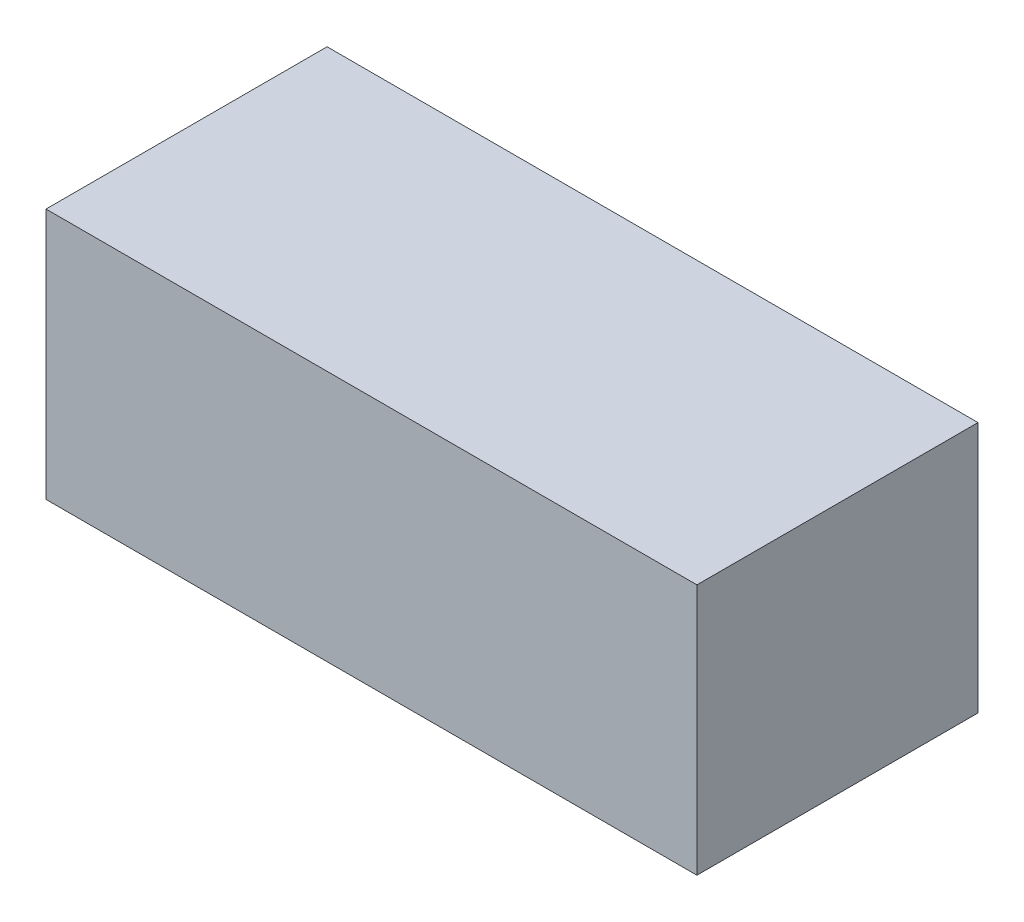
from build123d import *

# Parameters (mm, degrees)
SKETCH1_W           = 4.4
SKETCH1_H           = 1.9
BOSS_EXTRUDE1_DEPTH = 1.7


with BuildPart() as part:
    # Sketch1 → Boss-Extrude1 (new body)
    with BuildSketch(Plane(origin=(0, 0, 0), x_dir=(1, 0, 0), z_dir=(0, 1, 0))):
        with Locations((2.2, 0.95)):
            Rectangle(SKETCH1_W, SKETCH1_H)
    extrude(amount=BOSS_EXTRUDE1_DEPTH)


solid = part.part
